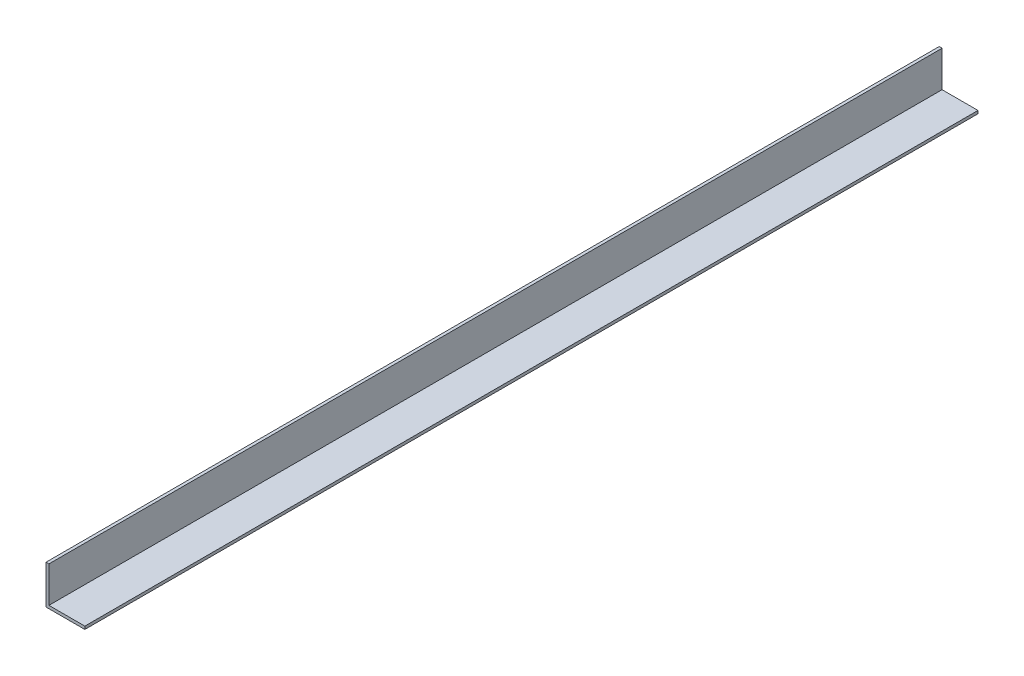
from build123d import *

# Parameters (mm, degrees)
EXTRUDE_THIN1_DEPTH = 230


with BuildPart() as part:
    # Sketch1 → Extrude-Thin1 (new, symmetric)
    with BuildSketch(Plane.XY):
        Polygon((0, 20), (0, 0), (20, 0), (20, 1.5), (1.5, 1.5), (1.5, 20), align=None)
    extrude(amount=EXTRUDE_THIN1_DEPTH, both=True)


solid = part.part
